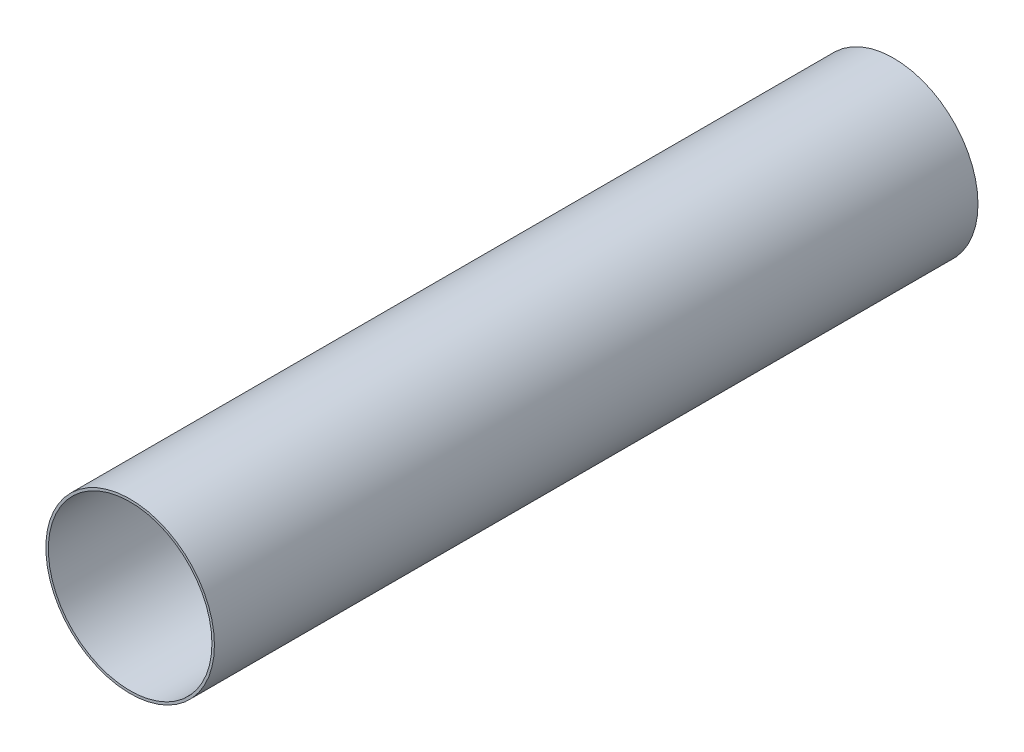
from build123d import *

# Parameters (mm, degrees)
SKETCH1_R           = 39.2557
SKETCH1_R_2         = 38.1
BOSS_EXTRUDE1_DEPTH = 177.8


with BuildPart() as part:
    # Sketch1 → Boss-Extrude1 (new body, symmetric)
    with BuildSketch(Plane.XY):
        Circle(SKETCH1_R)
        Circle(SKETCH1_R_2, mode=Mode.SUBTRACT)
    extrude(amount=BOSS_EXTRUDE1_DEPTH, both=True)


solid = part.part
